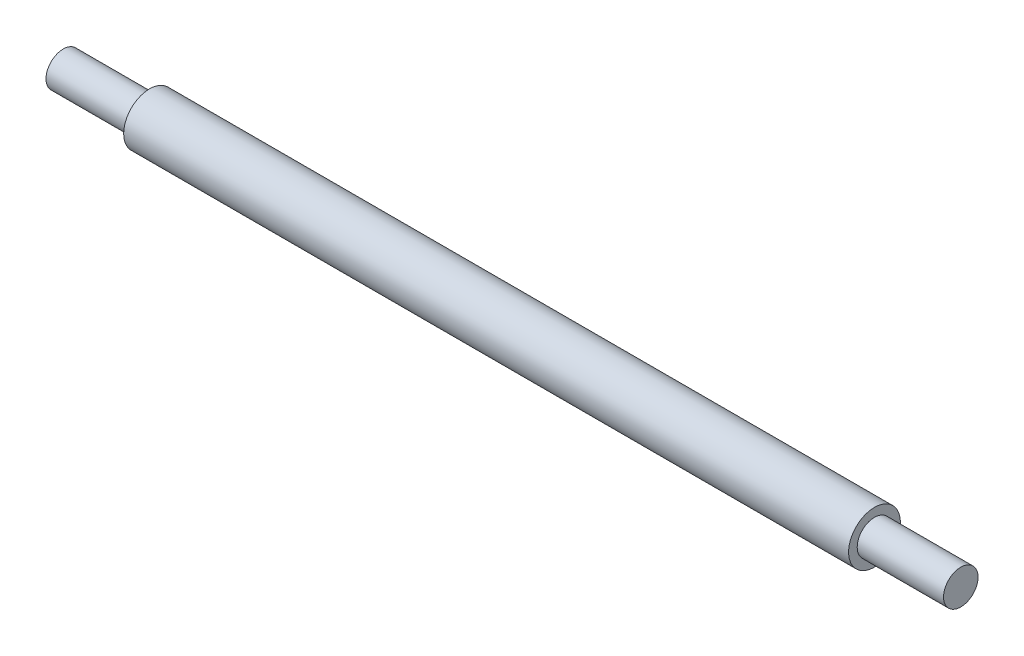
from build123d import *

# Parameters (mm, degrees)
SKETCH1_W = 10
SKETCH1_H = 2


with BuildPart() as part:
    # Sketch1 → Revolve1 (revolve)
    with BuildSketch(Plane.XY, mode=Mode.PRIVATE) as revolve1_sk:
        with Locations((5, 1)):
            Rectangle(SKETCH1_W, SKETCH1_H)
        Polygon((10, 2), (10, 0), (94, 0), (94, 2), (94, 3), (10, 3), align=None)
        with Locations((99, 1)):
            Rectangle(SKETCH1_W, SKETCH1_H)
    revolve(revolve1_sk.sketch.rotate(Axis((-71.687606112, 0, 0), (1, 0, 0)), 90), axis=Axis((-71.687606112, 0, 0), (1, 0, 0)))


solid = part.part
